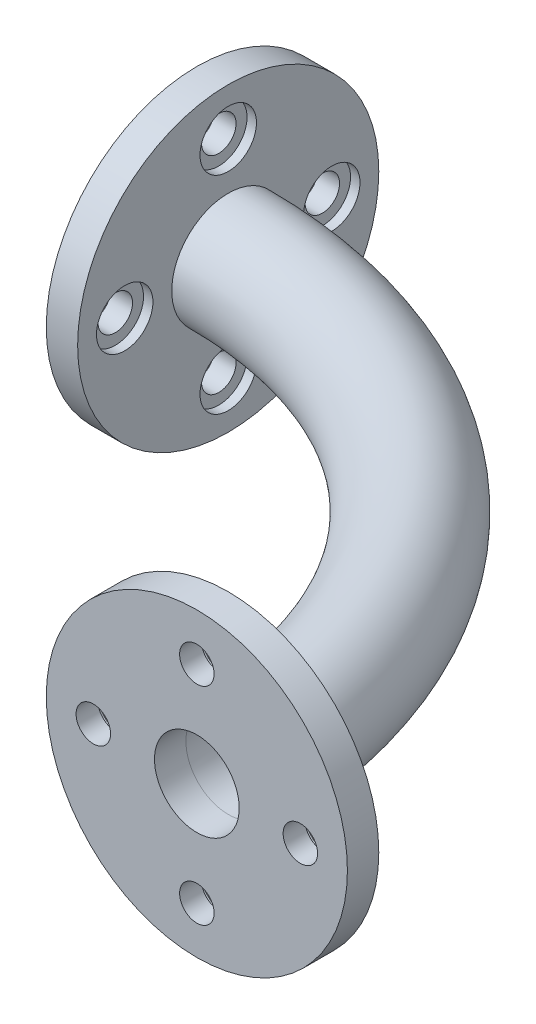
from build123d import *

# Parameters (mm, degrees)
CROQUIS2_R              = 48
CROQUIS2_R_2            = 13.5
CROQUIS2_R_3            = 5.5
SALIENTE_EXTRUIR1_DEPTH = 10
CROQUIS4_R              = 48
CROQUIS4_R_2            = 13.5
CROQUIS4_R_3            = 5.5
SALIENTE_EXTRUIR2_DEPTH = 10
CROQUIS6_R              = 18
CROQUIS6_R_2            = 13.5
CROQUIS8_R              = 9
CORTAR_EXTRUIR1_DEPTH   = 3
CROQUIS9_R              = 9
CORTAR_EXTRUIR2_DEPTH   = 3


with BuildPart() as part:
    # Croquis2 → Saliente-Extruir1 (new body)
    with BuildSketch(Plane(origin=(0, 0, 0), x_dir=(0, 0, -1), z_dir=(1, 0, 0))):
        Circle(CROQUIS2_R)
        Circle(CROQUIS2_R_2, mode=Mode.SUBTRACT)
        with Locations((0, 33)):
            Circle(CROQUIS2_R_3, mode=Mode.SUBTRACT)
        with Locations((33, 0)):
            Circle(CROQUIS2_R_3, mode=Mode.SUBTRACT)
        with Locations((0, -33)):
            Circle(CROQUIS2_R_3, mode=Mode.SUBTRACT)
        with Locations((-33, 0)):
            Circle(CROQUIS2_R_3, mode=Mode.SUBTRACT)
    extrude(amount=SALIENTE_EXTRUIR1_DEPTH)



with BuildPart() as body_2:
    # Croquis4 → Saliente-Extruir2 (new body)
    with BuildSketch(Plane.XY.offset(150)):
        with Locations((150, 0)):
            Circle(CROQUIS4_R)
        with Locations((150, 0)):
            Circle(CROQUIS4_R_2, mode=Mode.SUBTRACT)
        with Locations((150, 33)):
            Circle(CROQUIS4_R_3, mode=Mode.SUBTRACT)
        with Locations((183, 0)):
            Circle(CROQUIS4_R_3, mode=Mode.SUBTRACT)
        with Locations((150, -33)):
            Circle(CROQUIS4_R_3, mode=Mode.SUBTRACT)
        with Locations((117, 0)):
            Circle(CROQUIS4_R_3, mode=Mode.SUBTRACT)
    extrude(amount=-SALIENTE_EXTRUIR2_DEPTH)


with BuildPart() as part_1:
    add(part.part)

    add(body_2.part)  # Barrer1 merges body 2
    # Barrer1: sweep along a path in Croquis5
    with BuildLine(Plane(origin=(0, 0, 0), x_dir=(1, 0, 0), z_dir=(0, 1, 0))) as barrer1_path:
        ThreePointArc((10, 0), (108.994949366, -41.005050634), (150, -140))
    # Croquis6 → Barrer1 (sweep)
    with BuildSketch(Plane(origin=(10, 0, 0), x_dir=(0, 0, -1), z_dir=(1, 0, 0))):
        Circle(CROQUIS6_R)
        Circle(CROQUIS6_R_2, mode=Mode.SUBTRACT)
    sweep(path=barrer1_path.line)

    # Croquis8 → Cortar-Extruir1 (cut)
    with BuildSketch(Plane(origin=(10, 0, 0), x_dir=(0, 0, -1), z_dir=(1, 0, 0))):
        with Locations((0, 33)):
            Circle(CROQUIS8_R)
        with Locations((33, 0)):
            Circle(CROQUIS8_R)
        with Locations((0, -33)):
            Circle(CROQUIS8_R)
        with Locations((-33, 0)):
            Circle(CROQUIS8_R)
    extrude(amount=-CORTAR_EXTRUIR1_DEPTH, mode=Mode.SUBTRACT)

    # Croquis9 → Cortar-Extruir2 (cut)
    with BuildSketch(Plane(origin=(0, 0, 140), x_dir=(-1, 0, 0), z_dir=(0, 0, -1))):
        with Locations((-150, 33)):
            Circle(CROQUIS9_R)
        with Locations((-117, 0)):
            Circle(CROQUIS9_R)
        with Locations((-150, -33)):
            Circle(CROQUIS9_R)
        with Locations((-183, 0)):
            Circle(CROQUIS9_R)
    extrude(amount=-CORTAR_EXTRUIR2_DEPTH, mode=Mode.SUBTRACT)


solid = part_1.part
